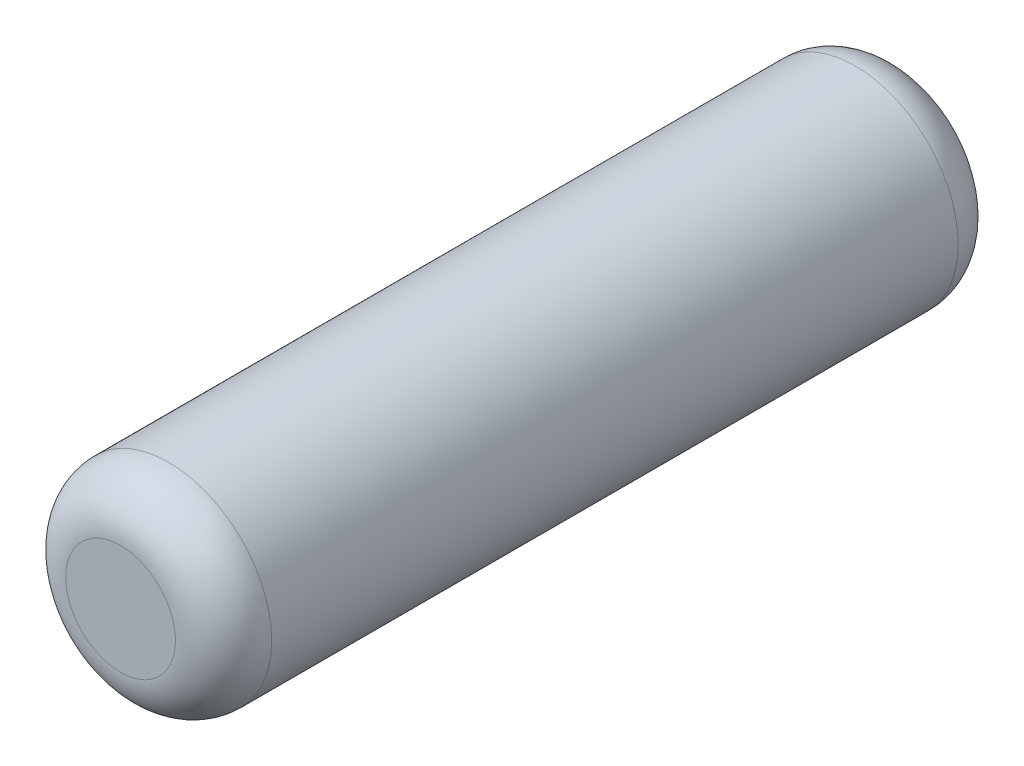
from build123d import *

# Parameters (mm, degrees)
SKETCH1_R           = 0.75
BOSS_EXTRUDE1_DEPTH = 2.85
FILLET1_R           = 0.35


with BuildPart() as part:
    # Sketch1 → Boss-Extrude1 (new body, symmetric)
    with BuildSketch(Plane.XY):
        Circle(SKETCH1_R)
    extrude(amount=BOSS_EXTRUDE1_DEPTH, both=True)

    # Fillet1
    fillet1_edges = [part.edges().sort_by_distance(p)[0] for p in [
        (-0.75, 0, -2.85),
        (-0.75, 0, 2.85),
    ]]
    fillet(fillet1_edges, radius=FILLET1_R)


solid = part.part
